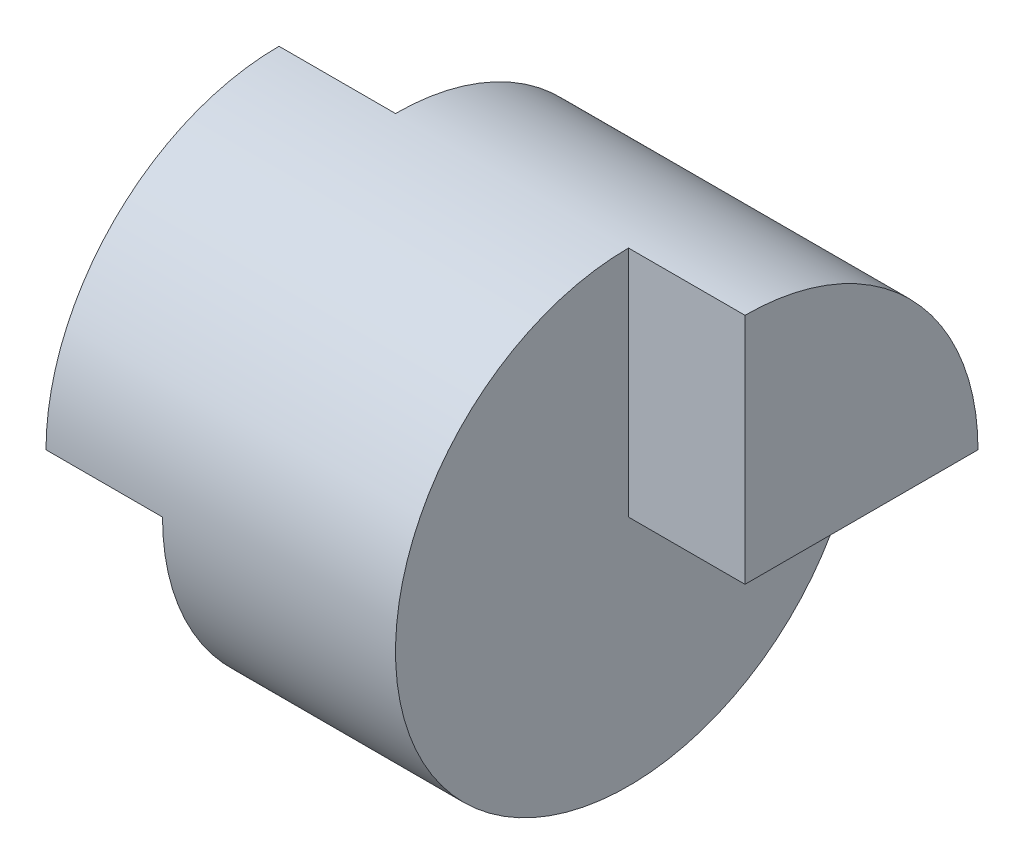
from build123d import *

# Parameters (mm, degrees)
SKETCH5_W          = 4
SKETCH5_H          = 2
SKETCH6_W          = 1
SKETCH6_H          = 2
CUT_EXTRUDE5_DEPTH = 5.5
SKETCH7_W          = 1
SKETCH7_H          = 2
CUT_EXTRUDE6_DEPTH = 10


with BuildPart() as part:
    # Sketch5 → Revolve-Thin2 (revolve)
    with BuildSketch(Plane.XY):
        with Locations((2, 1)):
            Rectangle(SKETCH5_W, SKETCH5_H)
    revolve(axis=Axis((0, 0, 0), (1, 0, 0)))

    # Sketch6 → Cut-Extrude5 (cut, symmetric)
    with BuildSketch(Plane.XY):
        with Locations((3.5, -1)):
            Rectangle(SKETCH6_W, SKETCH6_H)
        with Locations((0.5, -1)):
            Rectangle(SKETCH6_W, SKETCH6_H)
    extrude(amount=CUT_EXTRUDE5_DEPTH, both=True, mode=Mode.SUBTRACT)

    # Sketch7 → Cut-Extrude6 (cut)
    with BuildSketch(Plane.XZ):
        with Locations((0.5, -1)):
            Rectangle(SKETCH7_W, SKETCH7_H)
        with Locations((3.5, 1)):
            Rectangle(SKETCH7_W, SKETCH7_H)
    extrude(amount=-CUT_EXTRUDE6_DEPTH, mode=Mode.SUBTRACT)


solid = part.part
